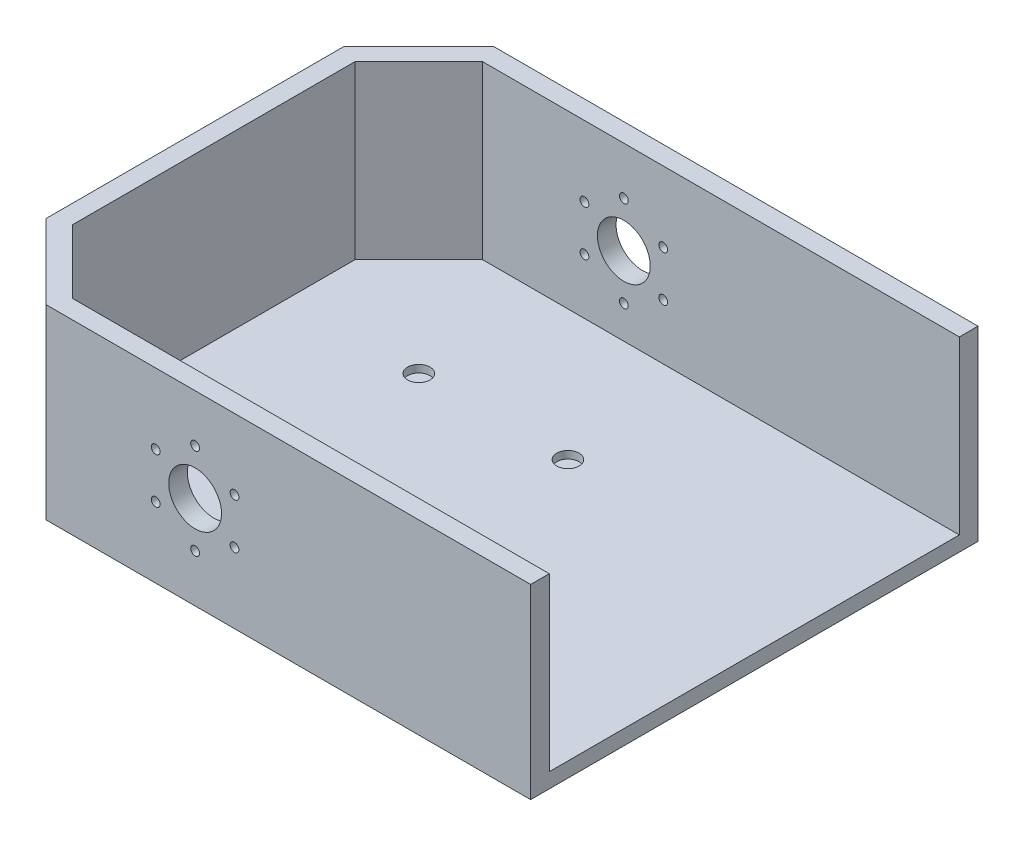
from build123d import *

# Parameters (mm, degrees)
SKETCH2_W           = 190.5
SKETCH2_H           = 152.4
BOSS_EXTRUDE1_DEPTH = 5.08
CHAMFER1_SIZE       = 25.4
BOSS_EXTRUDE3_DEPTH = 58.42
SKETCH5_R           = 9
SKETCH5_R_2         = 1.5
CUT_EXTRUDE1_DEPTH  = 153.4
SKETCH7_R           = 3.81
CUT_EXTRUDE2_DEPTH  = 2.54


with BuildPart() as part:
    # Sketch2 → Boss-Extrude1 (new body)
    with BuildSketch(Plane(origin=(0, 0, 0), x_dir=(1, 0, 0), z_dir=(0, 1, 0))):
        with Locations((-31.75, 0)):
            Rectangle(SKETCH2_W, SKETCH2_H)
    extrude(amount=BOSS_EXTRUDE1_DEPTH)

    # Chamfer1
    chamfer1_edges = [part.edges().sort_by_distance(p)[0] for p in [
        (-127, 2.54, -76.2),
        (-127, 2.54, 76.2),
    ]]
    chamfer(chamfer1_edges, length=CHAMFER1_SIZE)

    # Sketch4 → Boss-Extrude3 (add)
    with BuildSketch(Plane(origin=(0, 5.08, 0), x_dir=(1, 0, 0), z_dir=(0, 1, 0))):
        Polygon((57.15, 69.85), (-98.969743879, 69.85), (-120.65, 48.169743879), (-120.65, -48.169743879), (-98.969743879, -69.85), (57.15, -69.85), (63.5, -69.85), (63.5, -76.2), (-101.6, -76.2), (-127, -50.8), (-127, 50.8), (-101.6, 76.2), (63.5, 76.2), (63.5, 69.85), align=None)
    extrude(amount=BOSS_EXTRUDE3_DEPTH)

    # Sketch5 → Cut-Extrude1 (cut, through all)
    with BuildSketch(Plane.XY.offset(76.2)):
        with Locations((-50.8, 31.75)):
            Circle(SKETCH5_R)
        with Locations((-50.8, 47.25)):
            Circle(SKETCH5_R_2)
        with Locations((-37.376606241, 39.5)):
            Circle(SKETCH5_R_2)
        with Locations((-37.376606241, 24)):
            Circle(SKETCH5_R_2)
        with Locations((-50.8, 16.25)):
            Circle(SKETCH5_R_2)
        with Locations((-64.223393759, 24)):
            Circle(SKETCH5_R_2)
        with Locations((-64.223393759, 39.5)):
            Circle(SKETCH5_R_2)
    extrude(amount=-CUT_EXTRUDE1_DEPTH, mode=Mode.SUBTRACT)

    # Sketch7 → Cut-Extrude2 (cut)
    with BuildSketch(Plane(origin=(0, 5.08, 0), x_dir=(1, 0, 0), z_dir=(0, 1, 0))):
        with Locations((-76.2, 25.4)):
            Circle(SKETCH7_R)
        with Locations((-25.4, 25.4)):
            Circle(SKETCH7_R)
        with Locations((-25.4, -25.4)):
            Circle(SKETCH7_R)
        with Locations((-76.2, -25.4)):
            Circle(SKETCH7_R)
    extrude(amount=-CUT_EXTRUDE2_DEPTH, mode=Mode.SUBTRACT)


solid = part.part
